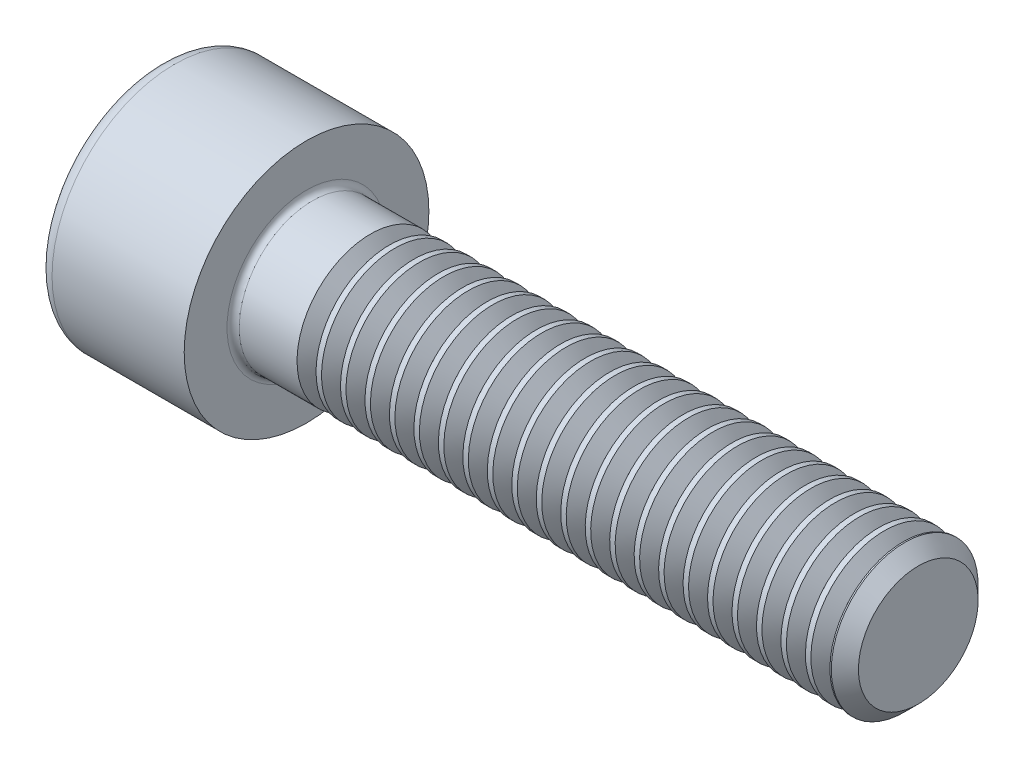
from build123d import *

# Parameters (mm, degrees)
FILLET1_R       = 0.25
FILLET2_R       = 0.6
HEX_2_DEPTH     = 3
THDSCHPAT_COUNT = 22
THDSCHPAT_PITCH = 1


with BuildPart() as part:
    # BodySke → Base-Revolve (revolve)
    with BuildSketch(Plane.XY):
        Polygon((0, 0), (0, 5), (6, 5), (6, 3), (30.4455, 3), (31, 2.4455), (31, 0), align=None)
    revolve(axis=Axis((-31.75, 0, 0), (1, 0, 0)))

    # Fillet1
    fillet1_edges = [part.edges().sort_by_distance(p)[0] for p in [
        (6, -3, 0),
    ]]
    fillet(fillet1_edges, radius=FILLET1_R)

    # Fillet2
    fillet2_edges = [part.edges().sort_by_distance(p)[0] for p in [
        (0, -5, 0),
    ]]
    fillet(fillet2_edges, radius=FILLET2_R)

    # Sketch2 → Hex-PreBroach (revolve, cut)
    with BuildSketch(Plane.XY):
        Polygon((0, 2.51), (3, 2.51), (4.449149176, 0), (0, 0), align=None)
    revolve(axis=Axis((0, 0, 0), (1, 0, 0)), mode=Mode.SUBTRACT)

    # Sketch3 → Hex 2 (cut)
    with BuildSketch(Plane(origin=(0, 0, 0), x_dir=(0, 0.5, 0.866025404), z_dir=(-1, 0, 0))):
        Polygon((1.449149176, 2.51), (-1.449149176, 2.51), (-2.898298351, 0), (-1.449149176, -2.51), (1.449149176, -2.51), (2.898298351, 0), align=None)
    extrude(amount=-HEX_2_DEPTH, mode=Mode.SUBTRACT)

    # ThdSchSke → ThreadSchematic (revolve, cut)
    with BuildSketch(Plane.XY):
        Polygon((9, -2.4455), (8.61173492, -3), (8.61173492, -3.75), (9.38826508, -3.75), (9.38826508, -3), align=None)
    threadschematic = revolve(axis=Axis((-3.175, 0, 0), (1, 0, 0)), mode=Mode.SUBTRACT)

    # ThdSchPat: ThreadSchematic ×22
    with Locations(*[(i * THDSCHPAT_PITCH, 0, 0) for i in range(1, THDSCHPAT_COUNT)]):
        add(threadschematic, mode=Mode.SUBTRACT)


solid = part.part
